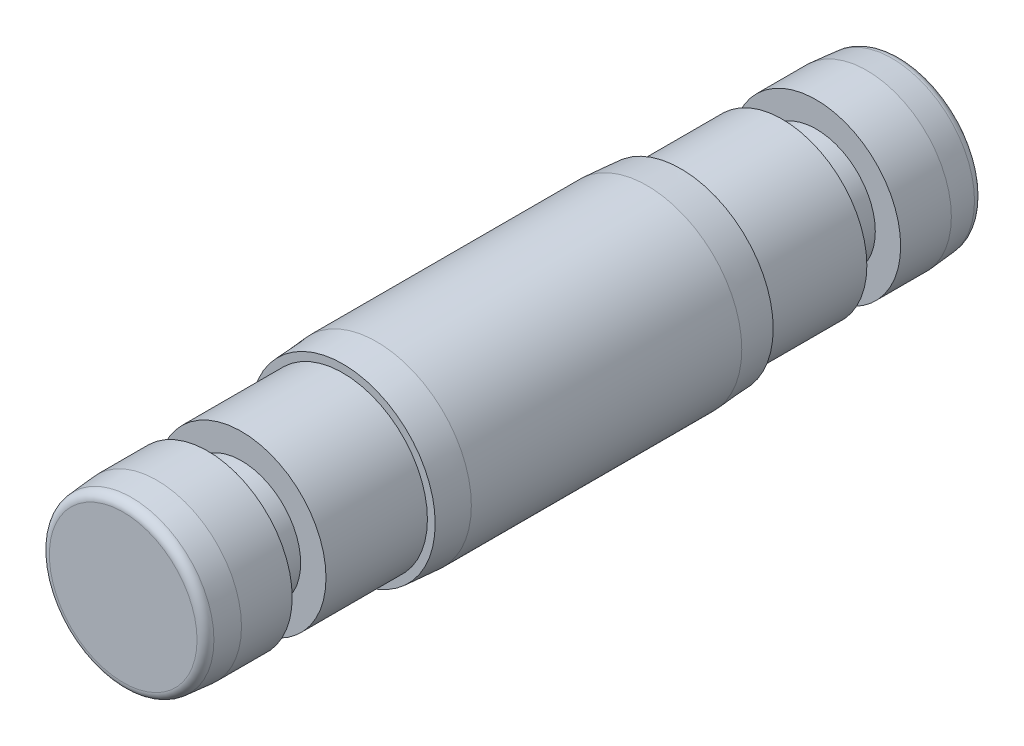
from build123d import *


with BuildPart() as part:
    # Sketch1 → Revolve1 (revolve)
    with BuildSketch(Plane(origin=(0, 0, 0), x_dir=(0, 0, -1), z_dir=(1, 0, 0))):
        with BuildLine():
            Line((-10, 0), (-3, 0))
            Line((-3, 0), (13, 0))
            Line((13, 0), (13, 5.6))
            Line((13, 5.6), (5, 5.6))
            Line((5, 5.6), (3, 5.460146376))
            Line((3, 5.460146376), (3, 5))
            Line((3, 5), (-3, 5))
            Line((-3, 5), (-3, 3.5))
            Line((-3, 3.5), (-5, 3.5))
            Line((-5, 3.5), (-5, 5))
            Line((-5, 5), (-8, 5))
            Line((-8, 5), (-9.5, 4.868767005))
            ThreePointArc((-9.5, 4.868767005), (-9.853553391, 4.722320395), (-10, 4.368767005))
            Line((-10, 4.368767005), (-10, 0))
        make_face()
    revolve1 = revolve(axis=Axis((0, 0, 3), (0, 0, -1)))

    # Mirror1: Revolve1 across plane
    add(revolve1.mirror(Plane(origin=(0, 0, -13), x_dir=(1, 0, 0), z_dir=(0, 0, -1))))


solid = part.part
